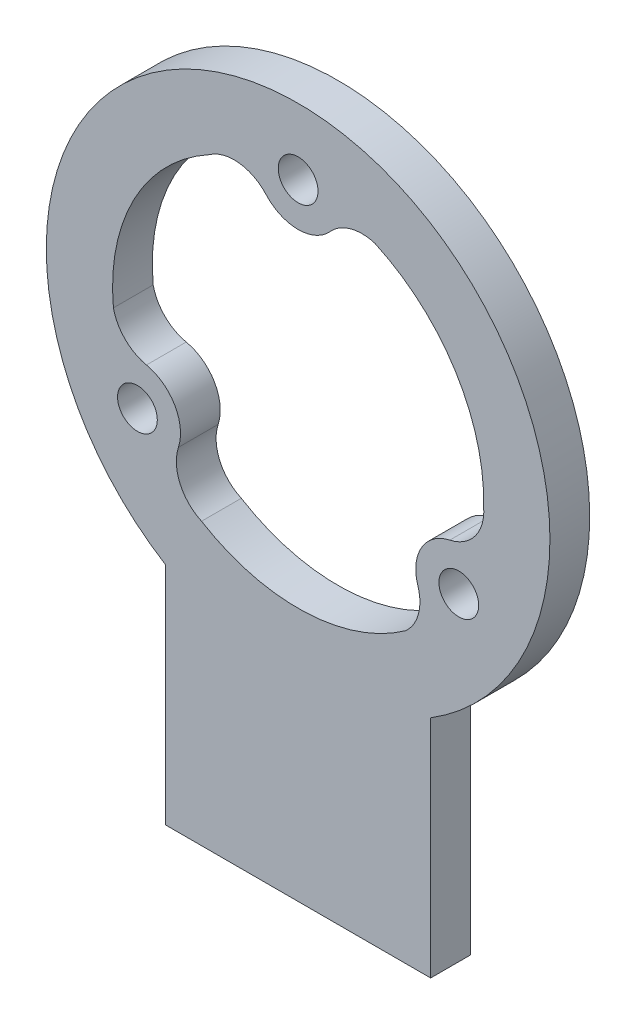
from build123d import *

# Parameters (mm, degrees)
ESQUISSE1_R        = 1.5
BOSS_EXTRU_2_DEPTH = 3


with BuildPart() as part:
    # Esquisse1 → Boss.-Extru.2 (new body)
    with BuildSketch(Plane.XY):
        with BuildLine():
            Line((10, -16.155494421), (10, -33.155494421))
            Line((10, -33.155494421), (-10, -33.155494421))
            Line((-10, -33.155494421), (-10, -16.155494421))
            ThreePointArc((-10, -16.155494421), (0, 19), (10, -16.155494421))
        make_face()
        with Locations((0, 14)):
            Circle(ESQUISSE1_R, mode=Mode.SUBTRACT)
        with Locations((12.124355653, -7)):
            Circle(ESQUISSE1_R, mode=Mode.SUBTRACT)
        with Locations((-12.124355653, -7)):
            Circle(ESQUISSE1_R, mode=Mode.SUBTRACT)
        with BuildLine():
            ThreePointArc((-2.411034891, 11.820685714), (0, 10.75), (2.411034891, 11.820685714))
            ThreePointArc((2.411034891, 11.820685714), (3.975330286, 12.779130538), (5.80943088, 12.737759334))
            ThreePointArc((5.80943088, 12.737759334), (11.865562564, 7.430237213), (13.995977593, -0.335575935))
            ThreePointArc((13.995977593, -0.335575935), (13.382779595, -2.564868949), (11.442531564, -3.822325392))
            ThreePointArc((11.442531564, -3.822325392), (9.309773091, -5.375), (9.031496673, -7.998360322))
            ThreePointArc((9.031496673, -7.998360322), (9.079386541, -9.832302285), (8.126507731, -11.399994391))
            ThreePointArc((8.126507731, -11.399994391), (0.5019929, -13.990997217), (-7.288606081, -11.953084179))
            ThreePointArc((-7.288606081, -11.953084179), (-8.912631465, -10.307392628), (-9.031496673, -7.998360322))
            ThreePointArc((-9.031496673, -7.998360322), (-9.309773091, -5.375), (-11.442531564, -3.822325392))
            ThreePointArc((-11.442531564, -3.822325392), (-13.054716827, -2.946828253), (-13.935938611, -1.337764944))
            ThreePointArc((-13.935938611, -1.337764944), (-12.367555464, 6.560760004), (-6.707371512, 12.288660114))
            ThreePointArc((-6.707371512, 12.288660114), (-4.47014813, 12.872261577), (-2.411034891, 11.820685714))
        make_face(mode=Mode.SUBTRACT)
    extrude(amount=BOSS_EXTRU_2_DEPTH)


solid = part.part
